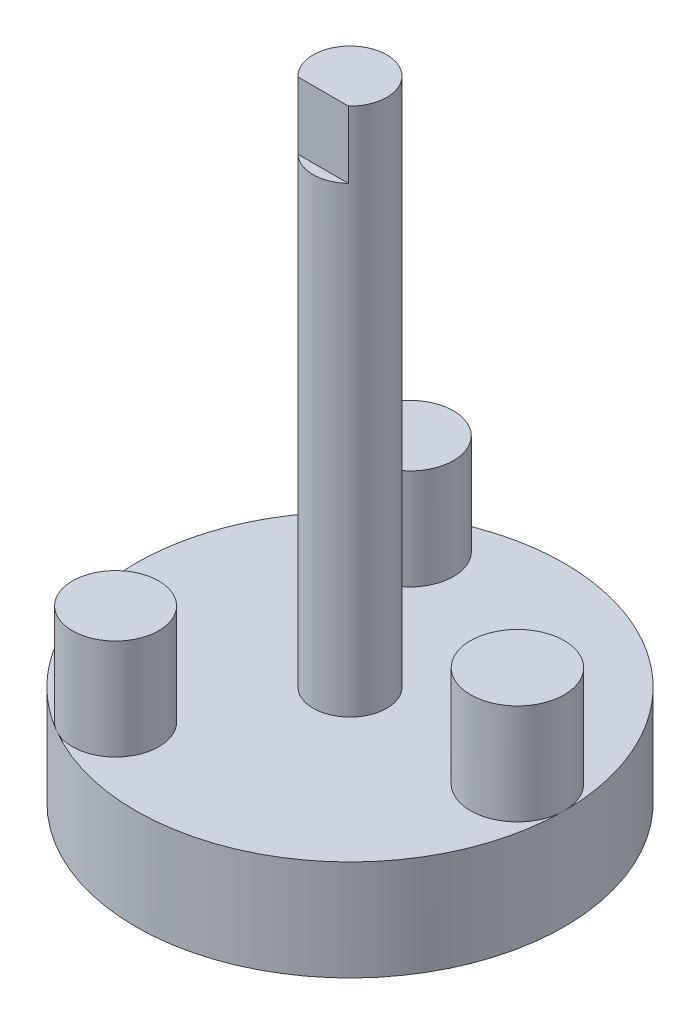
from build123d import *

# Parameters (mm, degrees)
SKETCH1_R               = 32
BOSS_EXTRUDE1_DEPTH     = 15
SKETCH2_R               = 7
SKETCH2_R_2             = 6.446135322
BOSS_EXTRUDE2_DEPTH     = 15
SKETCH3_R               = 5.5
BOSS_EXTRUDE3_DEPTH     = 79
CUT_EXTRUDE1_DEPTH      = 79
CUT_EXTRUDE1_DEPTH_BACK = 79


with BuildPart() as part:
    # Sketch1 → Boss-Extrude1 (new body)
    with BuildSketch(Plane(origin=(0, 0, 0), x_dir=(1, 0, 0), z_dir=(0, 1, 0))):
        Circle(SKETCH1_R)
    extrude(amount=BOSS_EXTRUDE1_DEPTH)

    # Sketch2 → Boss-Extrude2 (add)
    with BuildSketch(Plane(origin=(0, 15, 0), x_dir=(1, 0, 0), z_dir=(0, 1, 0))):
        with Locations((25, 0)):
            Circle(SKETCH2_R)
        with Locations((-13, 22)):
            Circle(SKETCH2_R_2)
        with Locations((-13, -22)):
            Circle(SKETCH2_R_2)
    extrude(amount=BOSS_EXTRUDE2_DEPTH)

    # Sketch3 → Boss-Extrude3 (add)
    with BuildSketch(Plane(origin=(0, 15, 0), x_dir=(1, 0, 0), z_dir=(0, 1, 0))):
        Circle(SKETCH3_R)
    extrude(amount=BOSS_EXTRUDE3_DEPTH)

    # Sketch4 → Cut-Extrude1 (cut, two sides: drawn at the far end of the back side and taken through both)
    with BuildSketch(Plane(origin=(0, 0, 0), x_dir=(0, 0, -1), z_dir=(1, 0, 0)).offset(-CUT_EXTRUDE1_DEPTH_BACK)):
        Polygon((-4.5, 84), (-8.757640736, 84), (-8.757640736, 94), (-4.5, 94), (-4, 94), (-4, 84), align=None)
    extrude(amount=CUT_EXTRUDE1_DEPTH + CUT_EXTRUDE1_DEPTH_BACK, mode=Mode.SUBTRACT)


solid = part.part
